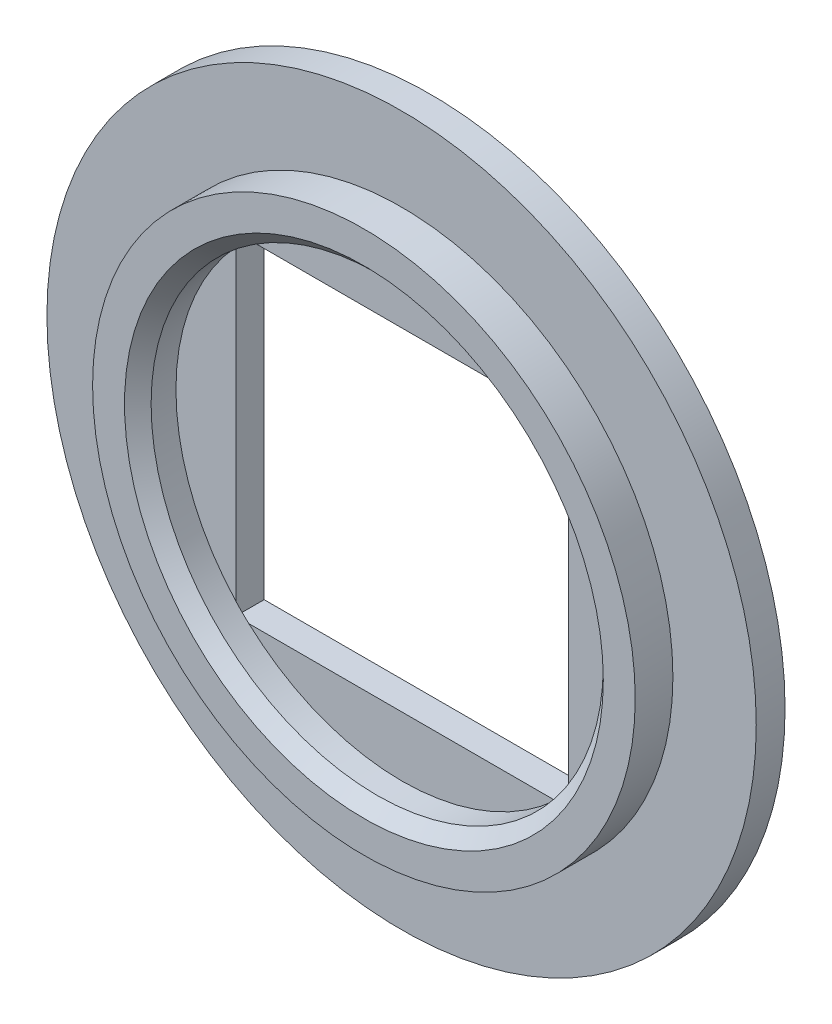
from build123d import *

# Parameters (mm, degrees)
SKETCH_1_R          = 8
EXTRUDE_1_DEPTH     = 0.65
EXTRUDE_START       = 0.65
SKETCH_2_R          = 6.12
SKETCH_2_R_2        = 5.1
EXTRUDE_2_DEPTH     = 0.85
CUT_EXTRUDE_START   = 0.65
SKETCH_3_R          = 5.1
CUT_EXTRUDE_1_DEPTH = 0.01
CUT_EXTRUDE_2_DEPTH = 0.64
CHAMFER_1_SIZE      = 0.3


with BuildPart() as part:
    # 草图1 → 凸台-拉伸1 (new body)
    with BuildSketch(Plane.XY):
        Circle(SKETCH_1_R)
    extrude(amount=EXTRUDE_1_DEPTH)

    # 草图2 → 凸台-拉伸2 (add)
    with BuildSketch(Plane.XY.offset(EXTRUDE_START)):
        Circle(SKETCH_2_R)
        Circle(SKETCH_2_R_2, mode=Mode.SUBTRACT)
    extrude(amount=EXTRUDE_2_DEPTH)

    # 草图3 → 切除-拉伸1 (cut)
    with BuildSketch(Plane.XY.offset(CUT_EXTRUDE_START)):
        Circle(SKETCH_3_R)
    extrude(amount=-CUT_EXTRUDE_1_DEPTH, mode=Mode.SUBTRACT)

    # 草图4 → 切除-拉伸2 (cut)
    with BuildSketch(Plane.XY):
        Polygon((3.75, 3.75), (3.75, -3.75), (-3.75, -3.75), (-3.75, 0), (-3.75, 3.75), align=None)
    extrude(amount=CUT_EXTRUDE_2_DEPTH, mode=Mode.SUBTRACT)

    # 倒角1
    chamfer_1_edges = [part.edges().sort_by_distance(p)[0] for p in [
        (-5.1, 0, 1.5),
    ]]
    chamfer(chamfer_1_edges, length=CHAMFER_1_SIZE)


solid = part.part
